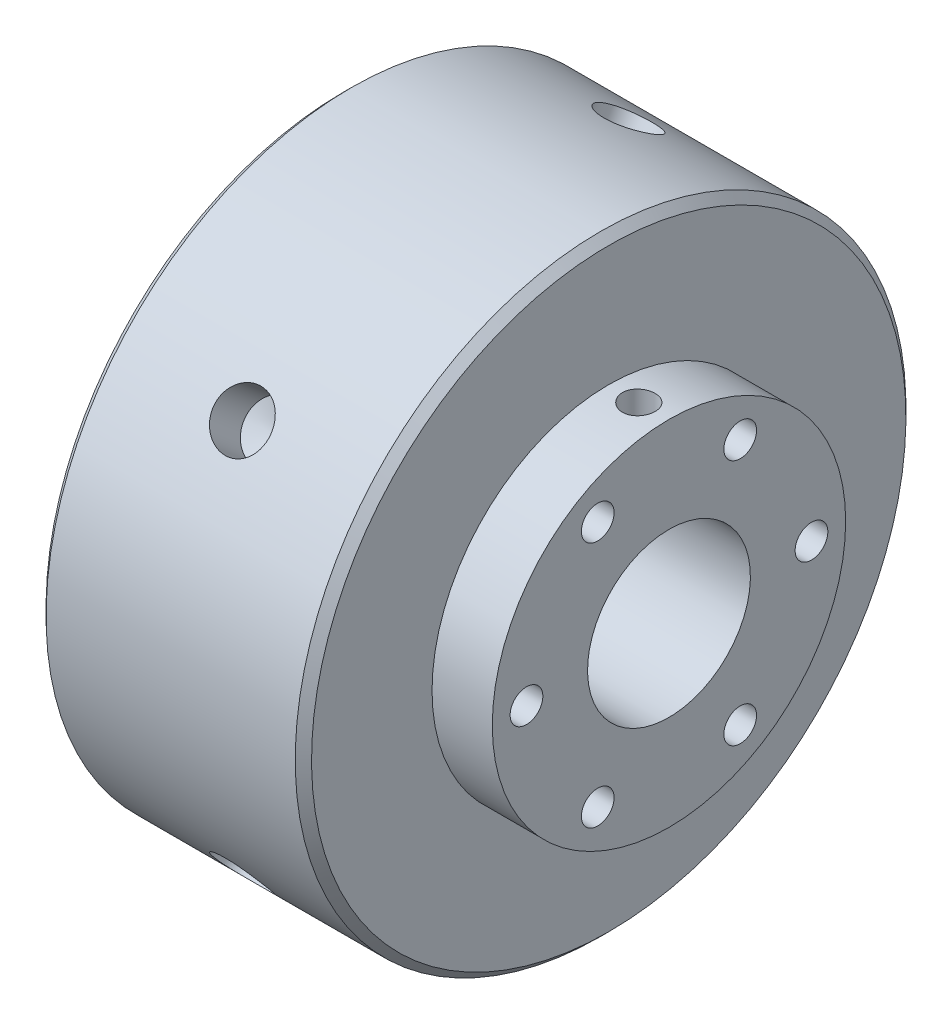
from build123d import *

# Parameters (mm, degrees)
SKETCH2_R                = 12.7
BORE_DEPTH               = 91.333163644
FACE_MOUNT_SCREWS_D      = 5.1054
SKETCH5_W                = 2.5527
SKETCH5_H                = 47.625
SET_SCREWS_AT_2_COUNT    = 2
SET_SCREWS_AT_2_PITCH    = 50.8
CHAMFER1_SIZE            = 1.27
SKETCH15_R               = 2.5
BOSS_EXTRUDE1_DEPTH      = 1
BOSS_EXTRUDE1_DEPTH_BACK = 20.32
SKETCH16_R               = 4.25
BOSS_EXTRUDE2_DEPTH      = 5
CHAMFER2_SIZE            = 0.381
CUT_EXTRUDE2_DEPTH       = 2
LPATTERN2_COUNT          = 2
LPATTERN2_PITCH          = 11.090402
LPATTERN2_2_COUNT        = 2
LPATTERN2_2_PITCH        = 11.090402
SKETCH18_R               = 27.559
SKETCH18_R_2             = 12.7
CUT_EXTRUDE3_DEPTH       = 0.0635
CIRPATTERN1_COUNT        = 4
CIRPATTERN1_ANGLE        = 240


with BuildPart() as part:
    # Sketch1 → Hub (revolve)
    with BuildSketch(Plane.XY, mode=Mode.PRIVATE) as hub_sk:
        Polygon((-20.701, 47.625), (20.701, 47.625), (20.701, 27.559), (30.099, 27.559), (30.099, 0), (-30.099, 0), (-30.099, 27.559), (-20.701, 27.559), align=None)
    revolve(hub_sk.sketch.rotate(Axis((-30.099, 0, 0), (1, 0, 0)), 180), axis=Axis((-30.099, 0, 0), (1, 0, 0)))

    # Sketch2 → Bore (cut, through all)
    with BuildSketch(Plane(origin=(30.099, 0, 0), x_dir=(0, 0, -1), z_dir=(1, 0, 0))):
        with Locations(Location((0, 0, 0), (0, 0, 90))):
            Circle(SKETCH2_R)
    extrude(amount=-BORE_DEPTH, mode=Mode.SUBTRACT)

    # Face Mount Screws (through all)
    with Locations(Plane(origin=(30.099, 0, 0), x_dir=(0, 0, -1), z_dir=(1, 0, 0))):
        with Locations((-22.225, 0), (11.1125, 19.247414599), (11.1125, -19.247414599), (-11.1125, -19.247414599), (22.225, 0), (-11.1125, 19.247414599)):
            Hole(FACE_MOUNT_SCREWS_D / 2)

    # Sketch5 → Set Screws (revolve, cut)
    with BuildSketch(Plane(origin=(-25.4, 0, 0), x_dir=(0, 0, -1), z_dir=(1, 0, 0))):
        with Locations((1.27635, 23.8125)):
            Rectangle(SKETCH5_W, SKETCH5_H)
    set_screws = revolve(axis=Axis((-25.4, -6.35, 0), (0, 1, 0)), mode=Mode.SUBTRACT)

    # Set Screws at 2: Set Screws ×2
    with Locations(*[(i * SET_SCREWS_AT_2_PITCH, 0, 0) for i in range(1, SET_SCREWS_AT_2_COUNT)]):
        add(set_screws, mode=Mode.SUBTRACT)

    # Chamfer1
    chamfer1_edges = [part.edges().sort_by_distance(p)[0] for p in [
        (-20.701, 47.625, 0),
        (20.701, 47.625, 0),
    ]]
    chamfer(chamfer1_edges, length=CHAMFER1_SIZE)

    # Sketch12 → Cut-Revolve1 (revolve, cut)
    with BuildSketch(Plane.XY.offset(-41.275), mode=Mode.PRIVATE) as cut_revolve1_sk:
        Polygon((-5, 47.625), (-5, 8), (-2.75, 8), (-2.75, -47.625), (0, -47.625), (0, 47.625), align=None)
    revolve(cut_revolve1_sk.sketch.rotate(Axis((0, -47.625, -41.275), (0, 1, 0)), 180), axis=Axis((0, -47.625, -41.275), (0, 1, 0)), mode=Mode.SUBTRACT)

    # Sketch14 → Cut-Revolve2 (revolve, cut)
    with BuildSketch(Plane.XY.offset(-41.275)):
        Polygon((-11.0905, -47.625), (-16.0905, -47.625), (-16.0905, -8), (-13.8405, -8), (-13.8405, 47.625), (-11.0905, 47.625), align=None)
    cut_revolve2 = revolve(axis=Axis((-11.0905, 47.625, -41.275), (0, -1, 0)), mode=Mode.SUBTRACT)

    # Mirror2: Cut-Revolve2 across plane
    add(cut_revolve2.mirror(Plane(origin=(0, 0, 0), x_dir=(0, 0, 1), z_dir=(1, 0, 0))), mode=Mode.SUBTRACT)

    # Sketch18 → Cut-Extrude3 (cut, symmetric)
    with BuildSketch(Plane(origin=(0, 0, 0), x_dir=(0, 0, -1), z_dir=(1, 0, 0))):
        with Locations(Location((0, 0, 0), (0, 0, 270))):
            Circle(SKETCH18_R)
        with Locations(Location((0, 0, 0), (0, 0, 90))):
            Circle(SKETCH18_R_2, mode=Mode.SUBTRACT)
    extrude(amount=CUT_EXTRUDE3_DEPTH, both=True, mode=Mode.SUBTRACT)

    # Sketch19 → R _0.339_ Diameter Hole1 (revolve, cut)
    with BuildSketch(Plane(origin=(0, -41.244459855, -23.8125), x_dir=(0, 0.499999999999998, -0.8660254037844399), z_dir=(1, 0, 0))):
        Polygon((0, 0), (0, 8.944516153), (4.318, 6.35), (4.318, 0), align=None)
    r_0_339_diameter_hole1 = revolve(axis=Axis((0, -46.743721169, -26.9875), (0, 0.8660254037844398, 0.49999999999999795)), mode=Mode.SUBTRACT)

    # CirPattern1: R _0.339_ Diameter Hole1 ×4 about axis
    cirpattern1_axis = Axis((-30.099, 0, 0), (-1, 0, 0))
    for i in range(1, CIRPATTERN1_COUNT):
        add(r_0_339_diameter_hole1.rotate(cirpattern1_axis, i * CIRPATTERN1_ANGLE / (CIRPATTERN1_COUNT - 1)), mode=Mode.SUBTRACT)


with BuildPart() as body_2:
    # Sketch15 → Boss-Extrude1 (new, two sides)
    with BuildSketch(Plane(origin=(0, 8, 0), x_dir=(1, 0, 0), z_dir=(0, 1, 0))) as boss_extrude1_sk:
        with Locations(Location((0, 41.275, 0), (0, 0, 180))):
            Circle(SKETCH15_R)
    extrude(amount=BOSS_EXTRUDE1_DEPTH)
    extrude(boss_extrude1_sk.sketch, amount=-BOSS_EXTRUDE1_DEPTH_BACK)

    # Sketch16 → Boss-Extrude2 (add)
    with BuildSketch(Plane(origin=(0, 9, 0), x_dir=(1, 0, 0), z_dir=(0, 1, 0))):
        with Locations(Location((0, 41.275, 0), (0, 0, 180))):
            Circle(SKETCH16_R)
    extrude(amount=BOSS_EXTRUDE2_DEPTH)

    # Chamfer2
    chamfer2_edges = [body_2.edges().sort_by_distance(p)[0] for p in [
        (2.5, -12.32, -41.275),
        (4.25, 14, -41.275),
    ]]
    chamfer(chamfer2_edges, length=CHAMFER2_SIZE)

    # Sketch17 → Cut-Extrude2 (cut)
    with BuildSketch(Plane(origin=(0, 14, 0), x_dir=(1, 0, 0), z_dir=(0, 1, 0))):
        Polygon((1.154700538, 43.275), (-1.154700538, 43.275), (-2.309401077, 41.275), (-1.154700538, 39.275), (1.154700538, 39.275), (2.309401077, 41.275), align=None)
    extrude(amount=-CUT_EXTRUDE2_DEPTH, mode=Mode.SUBTRACT)


with BuildPart() as lpattern2_1:
    # LPattern2: pattern copy
    add(body_2.part.moved(Location(Vector(1, 0, 0) * (1 * LPATTERN2_PITCH))))


with BuildPart() as lpattern2_2_1:
    # LPattern2 2: pattern copy
    add(body_2.part.moved(Location(Vector(-1, 0, 0) * (1 * LPATTERN2_2_PITCH))))


with BuildPart() as body_5:
    # Mirror4: mirrored copy
    add(lpattern2_1.part.mirror(Plane.ZX))


with BuildPart() as body_6:
    # Mirror4 2: mirrored copy
    add(lpattern2_2_1.part.mirror(Plane.ZX))


solid = Compound([part.part, body_2.part, body_5.part, body_6.part])
